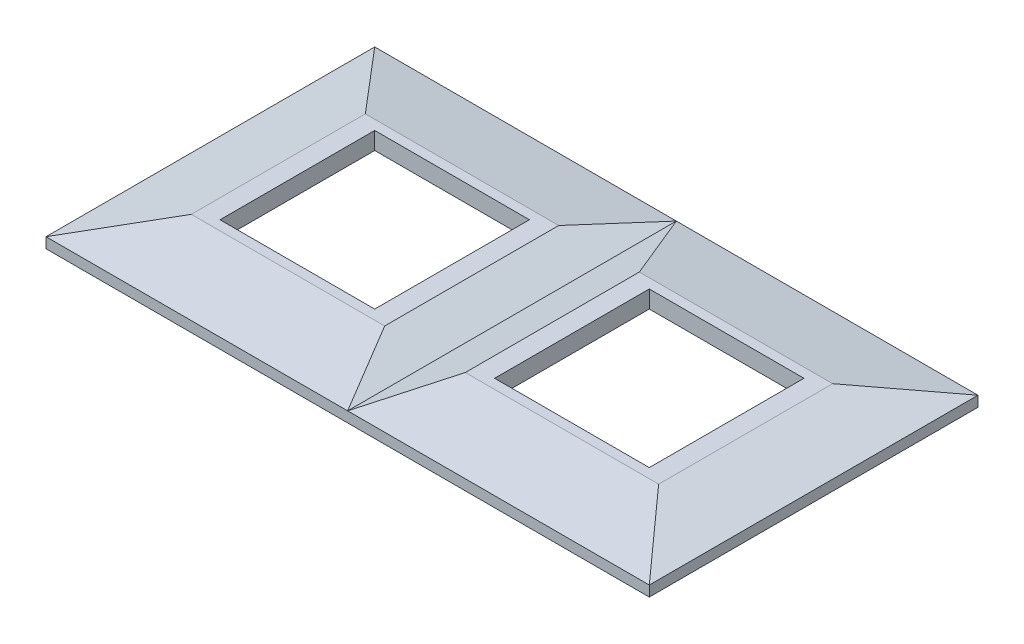
from build123d import *

# Parameters (mm, degrees)
EXTRUDE_1_DEPTH     = 42.5
SKETCH_2_OUTSIDE_W  = 122.554
SKETCH_2_OUTSIDE_H  = 44.054
CUT_EXTRUDE_1_DEPTH = 78
SKETCH_3_W          = 40
SKETCH_3_H          = 40
CUT_EXTRUDE_2_DEPTH = 7.5
SKETCH_4_W          = 152
SKETCH_4_H          = 82
CUT_EXTRUDE_3_DEPTH = 2


with BuildPart() as part:
    # Эскиз1 → Бобышка-Вытянуть1 (new body, symmetric)
    with BuildSketch(Plane.XY):
        Polygon((0, 0), (-78, 0), (-78, 2.705180544), (-60.423159652, 6.5), (-10.423159652, 6.5), (0, 2.705180544), (10.423159652, 6.5), (60.423159652, 6.5), (78, 2.705180544), (78, 0), align=None)
    extrude(amount=EXTRUDE_1_DEPTH, both=True)

    # Эскиз2 outside → Вырез-Вытянуть1 (cut, symmetric)
    with BuildSketch(Plane(origin=(0, 0, 0), x_dir=(0, 0, -1), z_dir=(1, 0, 0))):
        with Locations((0, 3.25)):
            Rectangle(SKETCH_2_OUTSIDE_W, SKETCH_2_OUTSIDE_H)
        Polygon((42.5, 0), (-42.5, 0), (-42.5, 2.705180544), (-22.5, 6.5), (22.5, 6.5), (42.5, 2.705180544), align=None, mode=Mode.SUBTRACT)
    extrude(amount=CUT_EXTRUDE_1_DEPTH, both=True, mode=Mode.SUBTRACT)

    # Эскиз3 → Вырез-Вытянуть2 (cut, through all)
    with BuildSketch(Plane.XZ):
        with Locations((-35.5, 0)):
            Rectangle(SKETCH_3_W, SKETCH_3_H)
        with Locations((35.5, 0)):
            Rectangle(SKETCH_3_W, SKETCH_3_H)
    extrude(amount=-CUT_EXTRUDE_2_DEPTH, mode=Mode.SUBTRACT)

    # Эскиз4 → Вырез-Вытянуть3 (cut)
    with BuildSketch(Plane.XZ):
        Rectangle(SKETCH_4_W, SKETCH_4_H)
    extrude(amount=-CUT_EXTRUDE_3_DEPTH, mode=Mode.SUBTRACT)


solid = part.part
